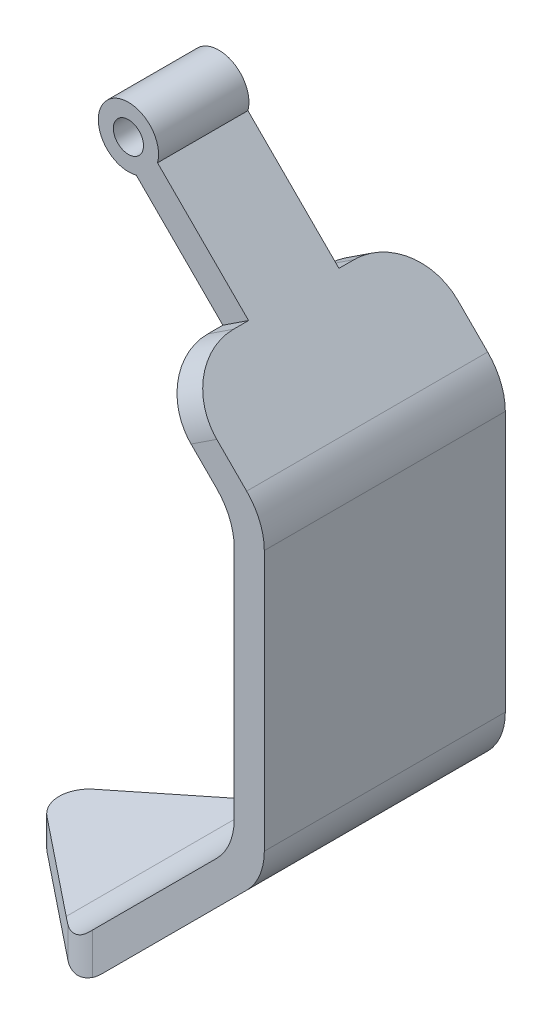
from build123d import *

# Parameters (mm, degrees)
SKETCH1_R           = 2.5
BOSS_EXTRUDE1_DEPTH = 20
SKETCH2_R           = 2.5
CUT_EXTRUDE1_DEPTH  = 12.5
CUT_EXTRUDE2_DEPTH  = 5
FILLET5_R           = 10
FILLET6_R           = 10
FILLET7_R           = 10
FILLET8_R           = 10
FILLET9_R           = 5


with BuildPart() as part:
    # Sketch1 → Boss-Extrude1 (new body)
    with BuildSketch(Plane.XY):
        with BuildLine():
            ThreePointArc((26.829629131, 51.705904774), (18.464466094, 56.535533906), (23.294095226, 48.170370869))
            Line((23.294095226, 48.170370869), (52.0520382, 19.412427894))
            Line((52.0520382, 19.412427894), (52.0520382, -27.9479618))
            Line((52.0520382, -27.9479618), (25, -55))
            Line((25, -55), (0, -55))
            Line((0, -55), (0, -60))
            Line((0, -60), (27.071067812, -60))
            Line((27.071067812, -60), (57.0520382, -30.019029611))
            Line((57.0520382, -30.019029611), (57.0520382, 21.483495706))
            Line((57.0520382, 21.483495706), (26.829629131, 51.705904774))
        make_face()
        with Locations((22, 53)):
            Circle(SKETCH1_R, mode=Mode.SUBTRACT)
    boss_extrude1 = extrude(amount=BOSS_EXTRUDE1_DEPTH)

    # Sketch2 → Cut-Extrude1 (cut)
    with BuildSketch(Plane.XY.offset(20)):
        with BuildLine():
            ThreePointArc((23.294095226, 48.170370869), (25.535533906, 49.464466094), (26.829629131, 51.705904774))
            ThreePointArc((26.829629131, 51.705904774), (26.957224307, 52.347369039), (27, 53))
            ThreePointArc((27, 53), (18.033233299, 56.043807145), (23.294095226, 48.170370869))
        make_face()
        with Locations((22, 53)):
            Circle(SKETCH2_R, mode=Mode.SUBTRACT)
        with BuildLine():
            Line((41.940833666, 36.59470024), (26.829629131, 51.705904774))
            ThreePointArc((26.829629131, 51.705904774), (25.535533906, 49.464466094), (23.294095226, 48.170370869))
            Line((23.294095226, 48.170370869), (37.673066713, 33.791399381))
            Line((37.673066713, 33.791399381), (41.940833666, 36.59470024))
        make_face()
    cut_extrude1 = extrude(amount=-CUT_EXTRUDE1_DEPTH, mode=Mode.SUBTRACT)

    # Sketch3 → Cut-Extrude2 (cut)
    with BuildSketch(Plane(origin=(0, -55, 0), x_dir=(1, 0, 0), z_dir=(0, 1, 0))):
        Polygon((25, -20), (0, 0), (0, -20), align=None)
    cut_extrude2 = extrude(amount=-CUT_EXTRUDE2_DEPTH, mode=Mode.SUBTRACT)

    # Mirror2: Boss-Extrude1, Cut-Extrude1, Cut-Extrude2 across plane
    add(boss_extrude1.mirror(Plane.XY))
    add(cut_extrude1.mirror(Plane.XY), mode=Mode.SUBTRACT)
    add(cut_extrude2.mirror(Plane.XY), mode=Mode.SUBTRACT)

    # Fillet5
    fillet5_edges = [part.edges().sort_by_distance(p)[0] for p in [
        (39.806950189, 35.193049811, -20),
        (39.806950189, 35.193049811, 20),
    ]]
    fillet(fillet5_edges, radius=FILLET5_R)

    # Fillet6
    fillet6_edges = [part.edges().sort_by_distance(p)[0] for p in [
        (27.071067812, -60, 0),
        (57.0520382, -30.019029611, 0),
        (57.0520382, 21.483495706, 0),
    ]]
    fillet(fillet6_edges, radius=FILLET6_R)

    # Fillet7
    fillet7_edges = [part.edges().sort_by_distance(p)[0] for p in [
        (25, -55, 0),
        (52.0520382, -27.9479618, 0),
        (52.0520382, 19.412427894, 0),
    ]]
    fillet(fillet7_edges, radius=FILLET7_R)

    # Fillet8
    fillet8_edges = [part.edges().sort_by_distance(p)[0] for p in [
        (25, -56.942490323, -20),
        (25, -56.942490323, 20),
    ]]
    fillet(fillet8_edges, radius=FILLET8_R)

    # Fillet9
    fillet9_edges = [part.edges().sort_by_distance(p)[0] for p in [
        (0, -57.5, 0),
    ]]
    fillet(fillet9_edges, radius=FILLET9_R)


solid = part.part
